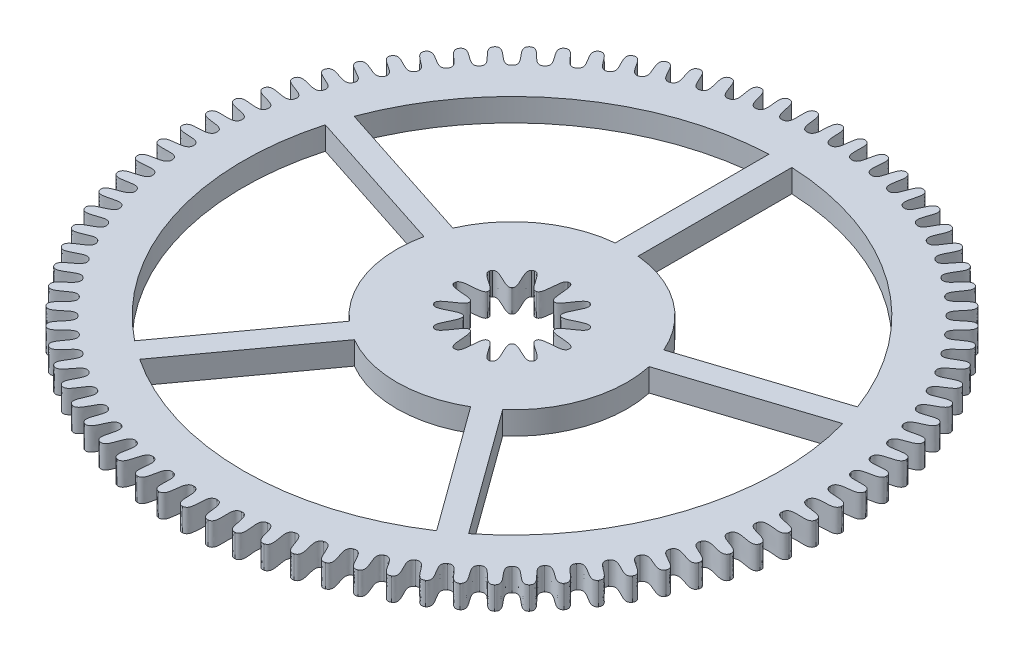
from build123d import *

# Parameters (mm, degrees)
BOSS_EXTRUDE1_84_TEETH_DEPTH = 0.3
CUT_EXTRUDE1_DEPTH           = 0.3
CUT_EXTRUDE2_REACH           = 2.3


with BuildPart() as part:
    # Sketch1 → Boss-Extrude1 (84 teeth) (new body)
    with BuildSketch(Plane(origin=(0, 0, 0), x_dir=(1, 0, 0), z_dir=(0, 1, 0))):
        with BuildLine():
            add(Edge.make_bspline(
                [(0, 4.315), (0.13525823, 4.312877026), (0.00799966, 4.016650924), (0.150125645, 4.01219233)],
                knots=[0, 0, 0, 0, 1, 1, 1, 1], degree=3))
            add(Edge.make_bspline(
                [(0.322460354, 4.302934385), (0.187421683, 4.310925207), (0.292187408, 4.006017369), (0.150125645, 4.01219233)],
                knots=[0, 0, 0, 0, 1, 1, 1, 1], degree=3))
            add(Edge.make_bspline(
                [(0.322460354, 4.302934385), (0.457181725, 4.290709487), (0.308141991, 4.004821739), (0.449537372, 3.989754523)],
                knots=[0, 0, 0, 0, 1, 1, 1, 1], degree=3))
            add(Edge.make_bspline(
                [(0.643117379, 4.266805015), (0.509053458, 4.284864946), (0.590740446, 3.97298054), (0.449537372, 3.989754523)],
                knots=[0, 0, 0, 0, 1, 1, 1, 1], degree=3))
            add(Edge.make_bspline(
                [(0.643117379, 4.266805015), (0.776548473, 4.24454656), (0.606561066, 3.970595965), (0.746435103, 3.94500439)],
                knots=[0, 0, 0, 0, 1, 1, 1, 1], degree=3))
            add(Edge.make_bspline(
                [(0.96017783, 4.206813941), (0.8278384, 4.234841982), (0.885989824, 3.917725192), (0.746435103, 3.94500439)],
                knots=[0, 0, 0, 0, 1, 1, 1, 1], degree=3))
            add(Edge.make_bspline(
                [(0.96017783, 4.206813941), (1.091572448, 4.174646407), (0.901588007, 3.914165008), (1.039158466, 3.878192193)],
                knots=[0, 0, 0, 0, 1, 1, 1, 1], degree=3))
            add(Edge.make_bspline(
                [(1.271868578, 4.123296657), (1.141993733, 4.161136064), (1.176284387, 3.840560335), (1.039158466, 3.878192193)],
                knots=[0, 0, 0, 0, 1, 1, 1, 1], degree=3))
            add(Edge.make_bspline(
                [(1.271868578, 4.123296657), (1.400491907, 4.081399938), (1.191572901, 3.835844453), (1.326070434, 3.789691571)],
                knots=[0, 0, 0, 0, 1, 1, 1, 1], degree=3))
            add(Edge.make_bspline(
                [(1.57644652, 4.016720225), (1.449762575, 4.064159385), (1.46000069, 3.741917507), (1.326070434, 3.789691571)],
                knots=[0, 0, 0, 0, 1, 1, 1, 1], degree=3))
            add(Edge.make_bspline(
                [(1.57644652, 4.016720225), (1.701579247, 3.965328624), (1.474894037, 3.736072299), (1.605566478, 3.679997457)],
                knots=[0, 0, 0, 0, 1, 1, 1, 1], degree=3))
            add(Edge.make_bspline(
                [(1.872208334, 3.887680665), (1.749423756, 3.944454278), (1.735552077, 3.622348358), (1.605566478, 3.679997457)],
                knots=[0, 0, 0, 0, 1, 1, 1, 1], degree=3))
            add(Edge.make_bspline(
                [(1.872208334, 3.887680665), (1.993150665, 3.827081585), (1.749966966, 3.615406514), (1.876083543, 3.549723305)],
                knots=[0, 0, 0, 0, 1, 1, 1, 1], degree=3))
            add(Edge.make_bspline(
                [(2.1575, 3.736899617), (2.03930145, 3.802690183), (2.001397554, 3.482521569), (1.876083543, 3.549723305)],
                knots=[0, 0, 0, 0, 1, 1, 1, 1], degree=3))
            add(Edge.make_bspline(
                [(2.1575, 3.736899617), (2.273575577, 3.667431953), (2.015253371, 3.474521909), (2.136108787, 3.39959766)],
                knots=[0, 0, 0, 0, 1, 1, 1, 1], degree=3))
            add(Edge.make_bspline(
                [(2.430726051, 3.565220311), (2.317774542, 3.639659902), (2.256050403, 3.323219105), (2.136108787, 3.39959766)],
                knots=[0, 0, 0, 0, 1, 1, 1, 1], degree=3))
            add(Edge.make_bspline(
                [(2.430726051, 3.565220311), (2.541285731, 3.487272554), (2.269269661, 3.314206368), (2.384188045, 3.230460086)],
                knots=[0, 0, 0, 0, 1, 1, 1, 1], degree=3))
            add(Edge.make_bspline(
                [(2.690358495, 3.373602847), (2.5832857, 3.456275166), (2.498086503, 3.145331853), (2.384188045, 3.230460086)],
                knots=[0, 0, 0, 0, 1, 1, 1, 1], degree=3))
            add(Edge.make_bspline(
                [(2.690358495, 3.373602847), (2.794783985, 3.287610912), (2.510595275, 3.135356441), (2.618933956, 3.043256468)],
                knots=[0, 0, 0, 0, 1, 1, 1, 1], degree=3))
            add(Edge.make_bspline(
                [(2.934945363, 3.163118827), (2.834350076, 3.253561538), (2.72615229, 2.949854629), (2.618933956, 3.043256468)],
                knots=[0, 0, 0, 0, 1, 1, 1, 1], degree=3))
            add(Edge.make_bspline(
                [(2.934945363, 3.163118827), (3.032652673, 3.069563616), (2.737880622, 2.938972328), (2.839033726, 2.839033726)],
                knots=[0, 0, 0, 0, 1, 1, 1, 1], degree=3))
            add(Edge.make_bspline(
                [(3.163118827, 2.934945363), (3.069563616, 3.032652673), (2.938972328, 2.737880622), (2.839033726, 2.839033726)],
                knots=[0, 0, 0, 0, 1, 1, 1, 1], degree=3))
            add(Edge.make_bspline(
                [(3.163118827, 2.934945363), (3.253561538, 2.834350076), (2.949854629, 2.72615229), (3.043256468, 2.618933956)],
                knots=[0, 0, 0, 0, 1, 1, 1, 1], degree=3))
            add(Edge.make_bspline(
                [(3.373602847, 2.690358495), (3.287610912, 2.794783985), (3.135356441, 2.510595275), (3.043256468, 2.618933956)],
                knots=[0, 0, 0, 0, 1, 1, 1, 1], degree=3))
            add(Edge.make_bspline(
                [(3.373602847, 2.690358495), (3.456275166, 2.5832857), (3.145331853, 2.498086503), (3.230460086, 2.384188045)],
                knots=[0, 0, 0, 0, 1, 1, 1, 1], degree=3))
            add(Edge.make_bspline(
                [(3.565220311, 2.430726051), (3.487272554, 2.541285731), (3.314206368, 2.269269661), (3.230460086, 2.384188045)],
                knots=[0, 0, 0, 0, 1, 1, 1, 1], degree=3))
            add(Edge.make_bspline(
                [(3.565220311, 2.430726051), (3.639659902, 2.317774542), (3.323219105, 2.256050403), (3.39959766, 2.136108787)],
                knots=[0, 0, 0, 0, 1, 1, 1, 1], degree=3))
            add(Edge.make_bspline(
                [(3.736899617, 2.1575), (3.667431953, 2.273575577), (3.474521909, 2.015253371), (3.39959766, 2.136108787)],
                knots=[0, 0, 0, 0, 1, 1, 1, 1], degree=3))
            add(Edge.make_bspline(
                [(3.736899617, 2.1575), (3.802690183, 2.03930145), (3.482521569, 2.001397554), (3.549723305, 1.876083543)],
                knots=[0, 0, 0, 0, 1, 1, 1, 1], degree=3))
            add(Edge.make_bspline(
                [(3.887680665, 1.872208334), (3.827081585, 1.993150665), (3.615406514, 1.749966966), (3.549723305, 1.876083543)],
                knots=[0, 0, 0, 0, 1, 1, 1, 1], degree=3))
            add(Edge.make_bspline(
                [(3.887680665, 1.872208334), (3.944454278, 1.749423756), (3.622348358, 1.735552077), (3.679997457, 1.605566478)],
                knots=[0, 0, 0, 0, 1, 1, 1, 1], degree=3))
            add(Edge.make_bspline(
                [(4.016720225, 1.57644652), (3.965328624, 1.701579247), (3.736072299, 1.474894037), (3.679997457, 1.605566478)],
                knots=[0, 0, 0, 0, 1, 1, 1, 1], degree=3))
            add(Edge.make_bspline(
                [(4.016720225, 1.57644652), (4.064159385, 1.449762575), (3.741917507, 1.46000069), (3.789691571, 1.326070434)],
                knots=[0, 0, 0, 0, 1, 1, 1, 1], degree=3))
            add(Edge.make_bspline(
                [(4.123296657, 1.271868578), (4.081399938, 1.400491907), (3.835844453, 1.191572901), (3.789691571, 1.326070434)],
                knots=[0, 0, 0, 0, 1, 1, 1, 1], degree=3))
            add(Edge.make_bspline(
                [(4.123296657, 1.271868578), (4.161136064, 1.141993733), (3.840560335, 1.176284387), (3.878192193, 1.039158466)],
                knots=[0, 0, 0, 0, 1, 1, 1, 1], degree=3))
            add(Edge.make_bspline(
                [(4.206813941, 0.96017783), (4.174646407, 1.091572448), (3.914165008, 0.901588007), (3.878192193, 1.039158466)],
                knots=[0, 0, 0, 0, 1, 1, 1, 1], degree=3))
            add(Edge.make_bspline(
                [(4.206813941, 0.96017783), (4.234841982, 0.8278384), (3.917725192, 0.885989824), (3.94500439, 0.746435103)],
                knots=[0, 0, 0, 0, 1, 1, 1, 1], degree=3))
            add(Edge.make_bspline(
                [(4.266805015, 0.643117379), (4.24454656, 0.776548473), (3.970595965, 0.606561066), (3.94500439, 0.746435103)],
                knots=[0, 0, 0, 0, 1, 1, 1, 1], degree=3))
            add(Edge.make_bspline(
                [(4.266805015, 0.643117379), (4.284864946, 0.509053458), (3.97298054, 0.590740446), (3.989754523, 0.449537372)],
                knots=[0, 0, 0, 0, 1, 1, 1, 1], degree=3))
            add(Edge.make_bspline(
                [(4.302934385, 0.322460354), (4.290709487, 0.457181725), (4.004821739, 0.308141991), (3.989754523, 0.449537372)],
                knots=[0, 0, 0, 0, 1, 1, 1, 1], degree=3))
            add(Edge.make_bspline(
                [(4.302934385, 0.322460354), (4.310925207, 0.187421683), (4.006017369, 0.292187408), (4.01219233, 0.150125645)],
                knots=[0, 0, 0, 0, 1, 1, 1, 1], degree=3))
            add(Edge.make_bspline(
                [(4.315, 0), (4.312877026, 0.13525823), (4.016650924, 0.00799966), (4.01219233, 0.150125645)],
                knots=[0, 0, 0, 0, 1, 1, 1, 1], degree=3))
            add(Edge.make_bspline(
                [(4.315, 0), (4.312877026, -0.13525823), (4.016650924, -0.00799966), (4.01219233, -0.150125645)],
                knots=[0, 0, 0, 0, 1, 1, 1, 1], degree=3))
            add(Edge.make_bspline(
                [(4.302934385, -0.322460354), (4.310925207, -0.187421683), (4.006017369, -0.292187408), (4.01219233, -0.150125645)],
                knots=[0, 0, 0, 0, 1, 1, 1, 1], degree=3))
            add(Edge.make_bspline(
                [(4.302934385, -0.322460354), (4.290709487, -0.457181725), (4.004821739, -0.308141991), (3.989754523, -0.449537372)],
                knots=[0, 0, 0, 0, 1, 1, 1, 1], degree=3))
            add(Edge.make_bspline(
                [(4.266805015, -0.643117379), (4.284864946, -0.509053458), (3.97298054, -0.590740446), (3.989754523, -0.449537372)],
                knots=[0, 0, 0, 0, 1, 1, 1, 1], degree=3))
            add(Edge.make_bspline(
                [(4.266805015, -0.643117379), (4.24454656, -0.776548473), (3.970595965, -0.606561066), (3.94500439, -0.746435103)],
                knots=[0, 0, 0, 0, 1, 1, 1, 1], degree=3))
            add(Edge.make_bspline(
                [(4.206813941, -0.96017783), (4.234841982, -0.8278384), (3.917725192, -0.885989824), (3.94500439, -0.746435103)],
                knots=[0, 0, 0, 0, 1, 1, 1, 1], degree=3))
            add(Edge.make_bspline(
                [(4.206813941, -0.96017783), (4.174646407, -1.091572448), (3.914165008, -0.901588007), (3.878192193, -1.039158466)],
                knots=[0, 0, 0, 0, 1, 1, 1, 1], degree=3))
            add(Edge.make_bspline(
                [(4.123296657, -1.271868578), (4.161136064, -1.141993733), (3.840560335, -1.176284387), (3.878192193, -1.039158466)],
                knots=[0, 0, 0, 0, 1, 1, 1, 1], degree=3))
            add(Edge.make_bspline(
                [(4.123296657, -1.271868578), (4.081399938, -1.400491907), (3.835844453, -1.191572901), (3.789691571, -1.326070434)],
                knots=[0, 0, 0, 0, 1, 1, 1, 1], degree=3))
            add(Edge.make_bspline(
                [(4.016720225, -1.57644652), (4.064159385, -1.449762575), (3.741917507, -1.46000069), (3.789691571, -1.326070434)],
                knots=[0, 0, 0, 0, 1, 1, 1, 1], degree=3))
            add(Edge.make_bspline(
                [(4.016720225, -1.57644652), (3.965328624, -1.701579247), (3.736072299, -1.474894037), (3.679997457, -1.605566478)],
                knots=[0, 0, 0, 0, 1, 1, 1, 1], degree=3))
            add(Edge.make_bspline(
                [(3.887680665, -1.872208334), (3.944454278, -1.749423756), (3.622348358, -1.735552077), (3.679997457, -1.605566478)],
                knots=[0, 0, 0, 0, 1, 1, 1, 1], degree=3))
            add(Edge.make_bspline(
                [(3.887680665, -1.872208334), (3.827081585, -1.993150665), (3.615406514, -1.749966966), (3.549723305, -1.876083543)],
                knots=[0, 0, 0, 0, 1, 1, 1, 1], degree=3))
            add(Edge.make_bspline(
                [(3.736899617, -2.1575), (3.802690183, -2.03930145), (3.482521569, -2.001397554), (3.549723305, -1.876083543)],
                knots=[0, 0, 0, 0, 1, 1, 1, 1], degree=3))
            add(Edge.make_bspline(
                [(3.736899617, -2.1575), (3.667431953, -2.273575577), (3.474521909, -2.015253371), (3.39959766, -2.136108787)],
                knots=[0, 0, 0, 0, 1, 1, 1, 1], degree=3))
            add(Edge.make_bspline(
                [(3.565220311, -2.430726051), (3.639659902, -2.317774542), (3.323219105, -2.256050403), (3.39959766, -2.136108787)],
                knots=[0, 0, 0, 0, 1, 1, 1, 1], degree=3))
            add(Edge.make_bspline(
                [(3.565220311, -2.430726051), (3.487272554, -2.541285731), (3.314206368, -2.269269661), (3.230460086, -2.384188045)],
                knots=[0, 0, 0, 0, 1, 1, 1, 1], degree=3))
            add(Edge.make_bspline(
                [(3.373602847, -2.690358495), (3.456275166, -2.5832857), (3.145331853, -2.498086503), (3.230460086, -2.384188045)],
                knots=[0, 0, 0, 0, 1, 1, 1, 1], degree=3))
            add(Edge.make_bspline(
                [(3.373602847, -2.690358495), (3.287610912, -2.794783985), (3.135356441, -2.510595275), (3.043256468, -2.618933956)],
                knots=[0, 0, 0, 0, 1, 1, 1, 1], degree=3))
            add(Edge.make_bspline(
                [(3.163118827, -2.934945363), (3.253561538, -2.834350076), (2.949854629, -2.72615229), (3.043256468, -2.618933956)],
                knots=[0, 0, 0, 0, 1, 1, 1, 1], degree=3))
            add(Edge.make_bspline(
                [(3.163118827, -2.934945363), (3.069563616, -3.032652673), (2.938972328, -2.737880622), (2.839033726, -2.839033726)],
                knots=[0, 0, 0, 0, 1, 1, 1, 1], degree=3))
            add(Edge.make_bspline(
                [(2.934945363, -3.163118827), (3.032652673, -3.069563616), (2.737880622, -2.938972328), (2.839033726, -2.839033726)],
                knots=[0, 0, 0, 0, 1, 1, 1, 1], degree=3))
            add(Edge.make_bspline(
                [(2.934945363, -3.163118827), (2.834350076, -3.253561538), (2.72615229, -2.949854629), (2.618933956, -3.043256468)],
                knots=[0, 0, 0, 0, 1, 1, 1, 1], degree=3))
            add(Edge.make_bspline(
                [(2.690358495, -3.373602847), (2.794783985, -3.287610912), (2.510595275, -3.135356441), (2.618933956, -3.043256468)],
                knots=[0, 0, 0, 0, 1, 1, 1, 1], degree=3))
            add(Edge.make_bspline(
                [(2.690358495, -3.373602847), (2.5832857, -3.456275166), (2.498086503, -3.145331853), (2.384188045, -3.230460086)],
                knots=[0, 0, 0, 0, 1, 1, 1, 1], degree=3))
            add(Edge.make_bspline(
                [(2.430726051, -3.565220311), (2.541285731, -3.487272554), (2.269269661, -3.314206368), (2.384188045, -3.230460086)],
                knots=[0, 0, 0, 0, 1, 1, 1, 1], degree=3))
            add(Edge.make_bspline(
                [(2.430726051, -3.565220311), (2.317774542, -3.639659902), (2.256050403, -3.323219105), (2.136108787, -3.39959766)],
                knots=[0, 0, 0, 0, 1, 1, 1, 1], degree=3))
            add(Edge.make_bspline(
                [(2.1575, -3.736899617), (2.273575577, -3.667431953), (2.015253371, -3.474521909), (2.136108787, -3.39959766)],
                knots=[0, 0, 0, 0, 1, 1, 1, 1], degree=3))
            add(Edge.make_bspline(
                [(2.1575, -3.736899617), (2.03930145, -3.802690183), (2.001397554, -3.482521569), (1.876083543, -3.549723305)],
                knots=[0, 0, 0, 0, 1, 1, 1, 1], degree=3))
            add(Edge.make_bspline(
                [(1.872208334, -3.887680665), (1.993150665, -3.827081585), (1.749966966, -3.615406514), (1.876083543, -3.549723305)],
                knots=[0, 0, 0, 0, 1, 1, 1, 1], degree=3))
            add(Edge.make_bspline(
                [(1.872208334, -3.887680665), (1.749423756, -3.944454278), (1.735552077, -3.622348358), (1.605566478, -3.679997457)],
                knots=[0, 0, 0, 0, 1, 1, 1, 1], degree=3))
            add(Edge.make_bspline(
                [(1.57644652, -4.016720225), (1.701579247, -3.965328624), (1.474894037, -3.736072299), (1.605566478, -3.679997457)],
                knots=[0, 0, 0, 0, 1, 1, 1, 1], degree=3))
            add(Edge.make_bspline(
                [(1.57644652, -4.016720225), (1.449762575, -4.064159385), (1.46000069, -3.741917507), (1.326070434, -3.789691571)],
                knots=[0, 0, 0, 0, 1, 1, 1, 1], degree=3))
            add(Edge.make_bspline(
                [(1.271868578, -4.123296657), (1.400491907, -4.081399938), (1.191572901, -3.835844453), (1.326070434, -3.789691571)],
                knots=[0, 0, 0, 0, 1, 1, 1, 1], degree=3))
            add(Edge.make_bspline(
                [(1.271868578, -4.123296657), (1.141993733, -4.161136064), (1.176284387, -3.840560335), (1.039158466, -3.878192193)],
                knots=[0, 0, 0, 0, 1, 1, 1, 1], degree=3))
            add(Edge.make_bspline(
                [(0.96017783, -4.206813941), (1.091572448, -4.174646407), (0.901588007, -3.914165008), (1.039158466, -3.878192193)],
                knots=[0, 0, 0, 0, 1, 1, 1, 1], degree=3))
            add(Edge.make_bspline(
                [(0.96017783, -4.206813941), (0.8278384, -4.234841982), (0.885989824, -3.917725192), (0.746435103, -3.94500439)],
                knots=[0, 0, 0, 0, 1, 1, 1, 1], degree=3))
            add(Edge.make_bspline(
                [(0.643117379, -4.266805015), (0.776548473, -4.24454656), (0.606561066, -3.970595965), (0.746435103, -3.94500439)],
                knots=[0, 0, 0, 0, 1, 1, 1, 1], degree=3))
            add(Edge.make_bspline(
                [(0.643117379, -4.266805015), (0.509053458, -4.284864946), (0.590740446, -3.97298054), (0.449537372, -3.989754523)],
                knots=[0, 0, 0, 0, 1, 1, 1, 1], degree=3))
            add(Edge.make_bspline(
                [(0.322460354, -4.302934385), (0.457181725, -4.290709487), (0.308141991, -4.004821739), (0.449537372, -3.989754523)],
                knots=[0, 0, 0, 0, 1, 1, 1, 1], degree=3))
            add(Edge.make_bspline(
                [(0.322460354, -4.302934385), (0.187421683, -4.310925207), (0.292187408, -4.006017369), (0.150125645, -4.01219233)],
                knots=[0, 0, 0, 0, 1, 1, 1, 1], degree=3))
            add(Edge.make_bspline(
                [(0, -4.315), (0.13525823, -4.312877026), (0.00799966, -4.016650924), (0.150125645, -4.01219233)],
                knots=[0, 0, 0, 0, 1, 1, 1, 1], degree=3))
            add(Edge.make_bspline(
                [(0, -4.315), (-0.13525823, -4.312877026), (-0.00799966, -4.016650924), (-0.150125645, -4.01219233)],
                knots=[0, 0, 0, 0, 1, 1, 1, 1], degree=3))
            add(Edge.make_bspline(
                [(-0.322460354, -4.302934385), (-0.187421683, -4.310925207), (-0.292187408, -4.006017369), (-0.150125645, -4.01219233)],
                knots=[0, 0, 0, 0, 1, 1, 1, 1], degree=3))
            add(Edge.make_bspline(
                [(-0.322460354, -4.302934385), (-0.457181725, -4.290709487), (-0.308141991, -4.004821739), (-0.449537372, -3.989754523)],
                knots=[0, 0, 0, 0, 1, 1, 1, 1], degree=3))
            add(Edge.make_bspline(
                [(-0.643117379, -4.266805015), (-0.509053458, -4.284864946), (-0.590740446, -3.97298054), (-0.449537372, -3.989754523)],
                knots=[0, 0, 0, 0, 1, 1, 1, 1], degree=3))
            add(Edge.make_bspline(
                [(-0.643117379, -4.266805015), (-0.776548473, -4.24454656), (-0.606561066, -3.970595965), (-0.746435103, -3.94500439)],
                knots=[0, 0, 0, 0, 1, 1, 1, 1], degree=3))
            add(Edge.make_bspline(
                [(-0.96017783, -4.206813941), (-0.8278384, -4.234841982), (-0.885989824, -3.917725192), (-0.746435103, -3.94500439)],
                knots=[0, 0, 0, 0, 1, 1, 1, 1], degree=3))
            add(Edge.make_bspline(
                [(-0.96017783, -4.206813941), (-1.091572448, -4.174646407), (-0.901588007, -3.914165008), (-1.039158466, -3.878192193)],
                knots=[0, 0, 0, 0, 1, 1, 1, 1], degree=3))
            add(Edge.make_bspline(
                [(-1.271868578, -4.123296657), (-1.141993733, -4.161136064), (-1.176284387, -3.840560335), (-1.039158466, -3.878192193)],
                knots=[0, 0, 0, 0, 1, 1, 1, 1], degree=3))
            add(Edge.make_bspline(
                [(-1.271868578, -4.123296657), (-1.400491907, -4.081399938), (-1.191572901, -3.835844453), (-1.326070434, -3.789691571)],
                knots=[0, 0, 0, 0, 1, 1, 1, 1], degree=3))
            add(Edge.make_bspline(
                [(-1.57644652, -4.016720225), (-1.449762575, -4.064159385), (-1.46000069, -3.741917507), (-1.326070434, -3.789691571)],
                knots=[0, 0, 0, 0, 1, 1, 1, 1], degree=3))
            add(Edge.make_bspline(
                [(-1.57644652, -4.016720225), (-1.701579247, -3.965328624), (-1.474894037, -3.736072299), (-1.605566478, -3.679997457)],
                knots=[0, 0, 0, 0, 1, 1, 1, 1], degree=3))
            add(Edge.make_bspline(
                [(-1.872208334, -3.887680665), (-1.749423756, -3.944454278), (-1.735552077, -3.622348358), (-1.605566478, -3.679997457)],
                knots=[0, 0, 0, 0, 1, 1, 1, 1], degree=3))
            add(Edge.make_bspline(
                [(-1.872208334, -3.887680665), (-1.993150665, -3.827081585), (-1.749966966, -3.615406514), (-1.876083543, -3.549723305)],
                knots=[0, 0, 0, 0, 1, 1, 1, 1], degree=3))
            add(Edge.make_bspline(
                [(-2.1575, -3.736899617), (-2.03930145, -3.802690183), (-2.001397554, -3.482521569), (-1.876083543, -3.549723305)],
                knots=[0, 0, 0, 0, 1, 1, 1, 1], degree=3))
            add(Edge.make_bspline(
                [(-2.1575, -3.736899617), (-2.273575577, -3.667431953), (-2.015253371, -3.474521909), (-2.136108787, -3.39959766)],
                knots=[0, 0, 0, 0, 1, 1, 1, 1], degree=3))
            add(Edge.make_bspline(
                [(-2.430726051, -3.565220311), (-2.317774542, -3.639659902), (-2.256050403, -3.323219105), (-2.136108787, -3.39959766)],
                knots=[0, 0, 0, 0, 1, 1, 1, 1], degree=3))
            add(Edge.make_bspline(
                [(-2.430726051, -3.565220311), (-2.541285731, -3.487272554), (-2.269269661, -3.314206368), (-2.384188045, -3.230460086)],
                knots=[0, 0, 0, 0, 1, 1, 1, 1], degree=3))
            add(Edge.make_bspline(
                [(-2.690358495, -3.373602847), (-2.5832857, -3.456275166), (-2.498086503, -3.145331853), (-2.384188045, -3.230460086)],
                knots=[0, 0, 0, 0, 1, 1, 1, 1], degree=3))
            add(Edge.make_bspline(
                [(-2.690358495, -3.373602847), (-2.794783985, -3.287610912), (-2.510595275, -3.135356441), (-2.618933956, -3.043256468)],
                knots=[0, 0, 0, 0, 1, 1, 1, 1], degree=3))
            add(Edge.make_bspline(
                [(-2.934945363, -3.163118827), (-2.834350076, -3.253561538), (-2.72615229, -2.949854629), (-2.618933956, -3.043256468)],
                knots=[0, 0, 0, 0, 1, 1, 1, 1], degree=3))
            add(Edge.make_bspline(
                [(-2.934945363, -3.163118827), (-3.032652673, -3.069563616), (-2.737880622, -2.938972328), (-2.839033726, -2.839033726)],
                knots=[0, 0, 0, 0, 1, 1, 1, 1], degree=3))
            add(Edge.make_bspline(
                [(-3.163118827, -2.934945363), (-3.069563616, -3.032652673), (-2.938972328, -2.737880622), (-2.839033726, -2.839033726)],
                knots=[0, 0, 0, 0, 1, 1, 1, 1], degree=3))
            add(Edge.make_bspline(
                [(-3.163118827, -2.934945363), (-3.253561538, -2.834350076), (-2.949854629, -2.72615229), (-3.043256468, -2.618933956)],
                knots=[0, 0, 0, 0, 1, 1, 1, 1], degree=3))
            add(Edge.make_bspline(
                [(-3.373602847, -2.690358495), (-3.287610912, -2.794783985), (-3.135356441, -2.510595275), (-3.043256468, -2.618933956)],
                knots=[0, 0, 0, 0, 1, 1, 1, 1], degree=3))
            add(Edge.make_bspline(
                [(-3.373602847, -2.690358495), (-3.456275166, -2.5832857), (-3.145331853, -2.498086503), (-3.230460086, -2.384188045)],
                knots=[0, 0, 0, 0, 1, 1, 1, 1], degree=3))
            add(Edge.make_bspline(
                [(-3.565220311, -2.430726051), (-3.487272554, -2.541285731), (-3.314206368, -2.269269661), (-3.230460086, -2.384188045)],
                knots=[0, 0, 0, 0, 1, 1, 1, 1], degree=3))
            add(Edge.make_bspline(
                [(-3.565220311, -2.430726051), (-3.639659902, -2.317774542), (-3.323219105, -2.256050403), (-3.39959766, -2.136108787)],
                knots=[0, 0, 0, 0, 1, 1, 1, 1], degree=3))
            add(Edge.make_bspline(
                [(-3.736899617, -2.1575), (-3.667431953, -2.273575577), (-3.474521909, -2.015253371), (-3.39959766, -2.136108787)],
                knots=[0, 0, 0, 0, 1, 1, 1, 1], degree=3))
            add(Edge.make_bspline(
                [(-3.736899617, -2.1575), (-3.802690183, -2.03930145), (-3.482521569, -2.001397554), (-3.549723305, -1.876083543)],
                knots=[0, 0, 0, 0, 1, 1, 1, 1], degree=3))
            add(Edge.make_bspline(
                [(-3.887680665, -1.872208334), (-3.827081585, -1.993150665), (-3.615406514, -1.749966966), (-3.549723305, -1.876083543)],
                knots=[0, 0, 0, 0, 1, 1, 1, 1], degree=3))
            add(Edge.make_bspline(
                [(-3.887680665, -1.872208334), (-3.944454278, -1.749423756), (-3.622348358, -1.735552077), (-3.679997457, -1.605566478)],
                knots=[0, 0, 0, 0, 1, 1, 1, 1], degree=3))
            add(Edge.make_bspline(
                [(-4.016720225, -1.57644652), (-3.965328624, -1.701579247), (-3.736072299, -1.474894037), (-3.679997457, -1.605566478)],
                knots=[0, 0, 0, 0, 1, 1, 1, 1], degree=3))
            add(Edge.make_bspline(
                [(-4.016720225, -1.57644652), (-4.064159385, -1.449762575), (-3.741917507, -1.46000069), (-3.789691571, -1.326070434)],
                knots=[0, 0, 0, 0, 1, 1, 1, 1], degree=3))
            add(Edge.make_bspline(
                [(-4.123296657, -1.271868578), (-4.081399938, -1.400491907), (-3.835844453, -1.191572901), (-3.789691571, -1.326070434)],
                knots=[0, 0, 0, 0, 1, 1, 1, 1], degree=3))
            add(Edge.make_bspline(
                [(-4.123296657, -1.271868578), (-4.161136064, -1.141993733), (-3.840560335, -1.176284387), (-3.878192193, -1.039158466)],
                knots=[0, 0, 0, 0, 1, 1, 1, 1], degree=3))
            add(Edge.make_bspline(
                [(-4.206813941, -0.96017783), (-4.174646407, -1.091572448), (-3.914165008, -0.901588007), (-3.878192193, -1.039158466)],
                knots=[0, 0, 0, 0, 1, 1, 1, 1], degree=3))
            add(Edge.make_bspline(
                [(-4.206813941, -0.96017783), (-4.234841982, -0.8278384), (-3.917725192, -0.885989824), (-3.94500439, -0.746435103)],
                knots=[0, 0, 0, 0, 1, 1, 1, 1], degree=3))
            add(Edge.make_bspline(
                [(-4.266805015, -0.643117379), (-4.24454656, -0.776548473), (-3.970595965, -0.606561066), (-3.94500439, -0.746435103)],
                knots=[0, 0, 0, 0, 1, 1, 1, 1], degree=3))
            add(Edge.make_bspline(
                [(-4.266805015, -0.643117379), (-4.284864946, -0.509053458), (-3.97298054, -0.590740446), (-3.989754523, -0.449537372)],
                knots=[0, 0, 0, 0, 1, 1, 1, 1], degree=3))
            add(Edge.make_bspline(
                [(-4.302934385, -0.322460354), (-4.290709487, -0.457181725), (-4.004821739, -0.308141991), (-3.989754523, -0.449537372)],
                knots=[0, 0, 0, 0, 1, 1, 1, 1], degree=3))
            add(Edge.make_bspline(
                [(-4.302934385, -0.322460354), (-4.310925207, -0.187421683), (-4.006017369, -0.292187408), (-4.01219233, -0.150125645)],
                knots=[0, 0, 0, 0, 1, 1, 1, 1], degree=3))
            add(Edge.make_bspline(
                [(-4.315, 0), (-4.312877026, -0.13525823), (-4.016650924, -0.00799966), (-4.01219233, -0.150125645)],
                knots=[0, 0, 0, 0, 1, 1, 1, 1], degree=3))
            add(Edge.make_bspline(
                [(-4.315, 0), (-4.312877026, 0.13525823), (-4.016650924, 0.00799966), (-4.01219233, 0.150125645)],
                knots=[0, 0, 0, 0, 1, 1, 1, 1], degree=3))
            add(Edge.make_bspline(
                [(-4.302934385, 0.322460354), (-4.310925207, 0.187421683), (-4.006017369, 0.292187408), (-4.01219233, 0.150125645)],
                knots=[0, 0, 0, 0, 1, 1, 1, 1], degree=3))
            add(Edge.make_bspline(
                [(-4.302934385, 0.322460354), (-4.290709487, 0.457181725), (-4.004821739, 0.308141991), (-3.989754523, 0.449537372)],
                knots=[0, 0, 0, 0, 1, 1, 1, 1], degree=3))
            add(Edge.make_bspline(
                [(-4.266805015, 0.643117379), (-4.284864946, 0.509053458), (-3.97298054, 0.590740446), (-3.989754523, 0.449537372)],
                knots=[0, 0, 0, 0, 1, 1, 1, 1], degree=3))
            add(Edge.make_bspline(
                [(-4.266805015, 0.643117379), (-4.24454656, 0.776548473), (-3.970595965, 0.606561066), (-3.94500439, 0.746435103)],
                knots=[0, 0, 0, 0, 1, 1, 1, 1], degree=3))
            add(Edge.make_bspline(
                [(-4.206813941, 0.96017783), (-4.234841982, 0.8278384), (-3.917725192, 0.885989824), (-3.94500439, 0.746435103)],
                knots=[0, 0, 0, 0, 1, 1, 1, 1], degree=3))
            add(Edge.make_bspline(
                [(-4.206813941, 0.96017783), (-4.174646407, 1.091572448), (-3.914165008, 0.901588007), (-3.878192193, 1.039158466)],
                knots=[0, 0, 0, 0, 1, 1, 1, 1], degree=3))
            add(Edge.make_bspline(
                [(-4.123296657, 1.271868578), (-4.161136064, 1.141993733), (-3.840560335, 1.176284387), (-3.878192193, 1.039158466)],
                knots=[0, 0, 0, 0, 1, 1, 1, 1], degree=3))
            add(Edge.make_bspline(
                [(-4.123296657, 1.271868578), (-4.081399938, 1.400491907), (-3.835844453, 1.191572901), (-3.789691571, 1.326070434)],
                knots=[0, 0, 0, 0, 1, 1, 1, 1], degree=3))
            add(Edge.make_bspline(
                [(-4.016720225, 1.57644652), (-4.064159385, 1.449762575), (-3.741917507, 1.46000069), (-3.789691571, 1.326070434)],
                knots=[0, 0, 0, 0, 1, 1, 1, 1], degree=3))
            add(Edge.make_bspline(
                [(-4.016720225, 1.57644652), (-3.965328624, 1.701579247), (-3.736072299, 1.474894037), (-3.679997457, 1.605566478)],
                knots=[0, 0, 0, 0, 1, 1, 1, 1], degree=3))
            add(Edge.make_bspline(
                [(-3.887680665, 1.872208334), (-3.944454278, 1.749423756), (-3.622348358, 1.735552077), (-3.679997457, 1.605566478)],
                knots=[0, 0, 0, 0, 1, 1, 1, 1], degree=3))
            add(Edge.make_bspline(
                [(-3.887680665, 1.872208334), (-3.827081585, 1.993150665), (-3.615406514, 1.749966966), (-3.549723305, 1.876083543)],
                knots=[0, 0, 0, 0, 1, 1, 1, 1], degree=3))
            add(Edge.make_bspline(
                [(-3.736899617, 2.1575), (-3.802690183, 2.03930145), (-3.482521569, 2.001397554), (-3.549723305, 1.876083543)],
                knots=[0, 0, 0, 0, 1, 1, 1, 1], degree=3))
            add(Edge.make_bspline(
                [(-3.736899617, 2.1575), (-3.667431953, 2.273575577), (-3.474521909, 2.015253371), (-3.39959766, 2.136108787)],
                knots=[0, 0, 0, 0, 1, 1, 1, 1], degree=3))
            add(Edge.make_bspline(
                [(-3.565220311, 2.430726051), (-3.639659902, 2.317774542), (-3.323219105, 2.256050403), (-3.39959766, 2.136108787)],
                knots=[0, 0, 0, 0, 1, 1, 1, 1], degree=3))
            add(Edge.make_bspline(
                [(-3.565220311, 2.430726051), (-3.487272554, 2.541285731), (-3.314206368, 2.269269661), (-3.230460086, 2.384188045)],
                knots=[0, 0, 0, 0, 1, 1, 1, 1], degree=3))
            add(Edge.make_bspline(
                [(-3.373602847, 2.690358495), (-3.456275166, 2.5832857), (-3.145331853, 2.498086503), (-3.230460086, 2.384188045)],
                knots=[0, 0, 0, 0, 1, 1, 1, 1], degree=3))
            add(Edge.make_bspline(
                [(-3.373602847, 2.690358495), (-3.287610912, 2.794783985), (-3.135356441, 2.510595275), (-3.043256468, 2.618933956)],
                knots=[0, 0, 0, 0, 1, 1, 1, 1], degree=3))
            add(Edge.make_bspline(
                [(-3.163118827, 2.934945363), (-3.253561538, 2.834350076), (-2.949854629, 2.72615229), (-3.043256468, 2.618933956)],
                knots=[0, 0, 0, 0, 1, 1, 1, 1], degree=3))
            add(Edge.make_bspline(
                [(-3.163118827, 2.934945363), (-3.069563616, 3.032652673), (-2.938972328, 2.737880622), (-2.839033726, 2.839033726)],
                knots=[0, 0, 0, 0, 1, 1, 1, 1], degree=3))
            add(Edge.make_bspline(
                [(-2.934945363, 3.163118827), (-3.032652673, 3.069563616), (-2.737880622, 2.938972328), (-2.839033726, 2.839033726)],
                knots=[0, 0, 0, 0, 1, 1, 1, 1], degree=3))
            add(Edge.make_bspline(
                [(-2.934945363, 3.163118827), (-2.834350076, 3.253561538), (-2.72615229, 2.949854629), (-2.618933956, 3.043256468)],
                knots=[0, 0, 0, 0, 1, 1, 1, 1], degree=3))
            add(Edge.make_bspline(
                [(-2.690358495, 3.373602847), (-2.794783985, 3.287610912), (-2.510595275, 3.135356441), (-2.618933956, 3.043256468)],
                knots=[0, 0, 0, 0, 1, 1, 1, 1], degree=3))
            add(Edge.make_bspline(
                [(-2.690358495, 3.373602847), (-2.5832857, 3.456275166), (-2.498086503, 3.145331853), (-2.384188045, 3.230460086)],
                knots=[0, 0, 0, 0, 1, 1, 1, 1], degree=3))
            add(Edge.make_bspline(
                [(-2.430726051, 3.565220311), (-2.541285731, 3.487272554), (-2.269269661, 3.314206368), (-2.384188045, 3.230460086)],
                knots=[0, 0, 0, 0, 1, 1, 1, 1], degree=3))
            add(Edge.make_bspline(
                [(-2.430726051, 3.565220311), (-2.317774542, 3.639659902), (-2.256050403, 3.323219105), (-2.136108787, 3.39959766)],
                knots=[0, 0, 0, 0, 1, 1, 1, 1], degree=3))
            add(Edge.make_bspline(
                [(-2.1575, 3.736899617), (-2.273575577, 3.667431953), (-2.015253371, 3.474521909), (-2.136108787, 3.39959766)],
                knots=[0, 0, 0, 0, 1, 1, 1, 1], degree=3))
            add(Edge.make_bspline(
                [(-2.1575, 3.736899617), (-2.03930145, 3.802690183), (-2.001397554, 3.482521569), (-1.876083543, 3.549723305)],
                knots=[0, 0, 0, 0, 1, 1, 1, 1], degree=3))
            add(Edge.make_bspline(
                [(-1.872208334, 3.887680665), (-1.993150665, 3.827081585), (-1.749966966, 3.615406514), (-1.876083543, 3.549723305)],
                knots=[0, 0, 0, 0, 1, 1, 1, 1], degree=3))
            add(Edge.make_bspline(
                [(-1.872208334, 3.887680665), (-1.749423756, 3.944454278), (-1.735552077, 3.622348358), (-1.605566478, 3.679997457)],
                knots=[0, 0, 0, 0, 1, 1, 1, 1], degree=3))
            add(Edge.make_bspline(
                [(-1.57644652, 4.016720225), (-1.701579247, 3.965328624), (-1.474894037, 3.736072299), (-1.605566478, 3.679997457)],
                knots=[0, 0, 0, 0, 1, 1, 1, 1], degree=3))
            add(Edge.make_bspline(
                [(-1.57644652, 4.016720225), (-1.449762575, 4.064159385), (-1.46000069, 3.741917507), (-1.326070434, 3.789691571)],
                knots=[0, 0, 0, 0, 1, 1, 1, 1], degree=3))
            add(Edge.make_bspline(
                [(-1.271868578, 4.123296657), (-1.400491907, 4.081399938), (-1.191572901, 3.835844453), (-1.326070434, 3.789691571)],
                knots=[0, 0, 0, 0, 1, 1, 1, 1], degree=3))
            add(Edge.make_bspline(
                [(-1.271868578, 4.123296657), (-1.141993733, 4.161136064), (-1.176284387, 3.840560335), (-1.039158466, 3.878192193)],
                knots=[0, 0, 0, 0, 1, 1, 1, 1], degree=3))
            add(Edge.make_bspline(
                [(-0.96017783, 4.206813941), (-1.091572448, 4.174646407), (-0.901588007, 3.914165008), (-1.039158466, 3.878192193)],
                knots=[0, 0, 0, 0, 1, 1, 1, 1], degree=3))
            add(Edge.make_bspline(
                [(-0.96017783, 4.206813941), (-0.8278384, 4.234841982), (-0.885989824, 3.917725192), (-0.746435103, 3.94500439)],
                knots=[0, 0, 0, 0, 1, 1, 1, 1], degree=3))
            add(Edge.make_bspline(
                [(-0.643117379, 4.266805015), (-0.776548473, 4.24454656), (-0.606561066, 3.970595965), (-0.746435103, 3.94500439)],
                knots=[0, 0, 0, 0, 1, 1, 1, 1], degree=3))
            add(Edge.make_bspline(
                [(-0.643117379, 4.266805015), (-0.509053458, 4.284864946), (-0.590740446, 3.97298054), (-0.449537372, 3.989754523)],
                knots=[0, 0, 0, 0, 1, 1, 1, 1], degree=3))
            add(Edge.make_bspline(
                [(-0.322460354, 4.302934385), (-0.457181725, 4.290709487), (-0.308141991, 4.004821739), (-0.449537372, 3.989754523)],
                knots=[0, 0, 0, 0, 1, 1, 1, 1], degree=3))
            add(Edge.make_bspline(
                [(-0.322460354, 4.302934385), (-0.187421683, 4.310925207), (-0.292187408, 4.006017369), (-0.150125645, 4.01219233)],
                knots=[0, 0, 0, 0, 1, 1, 1, 1], degree=3))
            add(Edge.make_bspline(
                [(0, 4.315), (-0.13525823, 4.312877026), (-0.00799966, 4.016650924), (-0.150125645, 4.01219233)],
                knots=[0, 0, 0, 0, 1, 1, 1, 1], degree=3))
        make_face()
    extrude(amount=BOSS_EXTRUDE1_84_TEETH_DEPTH)

    # Sketch2 → Cut-Extrude1 (cut)
    with BuildSketch(Plane(origin=(0, 0, 0), x_dir=(1, 0, 0), z_dir=(0, 1, 0))):
        with BuildLine():
            Line((0, 0.75), (0.01499925, 0.74985))
            add(Edge.make_bspline(
                [(0.01499925, 0.74985), (0.089770208, 0.726526589), (0.037536283, 0.45058181), (0.11646857, 0.434666622)],
                knots=[0, 0, 0, 0, 1, 1, 1, 1], degree=3))
            add(Edge.make_bspline(
                [(0.361935268, 0.656888774), (0.27667218, 0.679442999), (0.19278353, 0.408983436), (0.11646857, 0.434666622)],
                knots=[0, 0, 0, 0, 1, 1, 1, 1], degree=3))
            Line((0.361935268, 0.656888774), (0.375, 0.649519053))
            Line((0.375, 0.649519053), (0.387914732, 0.641889524))
            add(Edge.make_bspline(
                [(0.387914732, 0.641889524), (0.450078807, 0.579326636), (0.25779828, 0.371447153), (0.318198052, 0.318198052)],
                knots=[0, 0, 0, 0, 1, 1, 1, 1], degree=3))
            add(Edge.make_bspline(
                [(0.641889524, 0.387914732), (0.579326636, 0.450078807), (0.371447153, 0.25779828), (0.318198052, 0.318198052)],
                knots=[0, 0, 0, 0, 1, 1, 1, 1], degree=3))
            Line((0.641889524, 0.387914732), (0.649519053, 0.375))
            Line((0.649519053, 0.375), (0.656888774, 0.361935268))
            add(Edge.make_bspline(
                [(0.656888774, 0.361935268), (0.679442999, 0.27667218), (0.408983436, 0.19278353), (0.434666622, 0.11646857)],
                knots=[0, 0, 0, 0, 1, 1, 1, 1], degree=3))
            add(Edge.make_bspline(
                [(0.74985, 0.01499925), (0.726750987, 0.100116363), (0.45058181, 0.037536283), (0.434666622, 0.11646857)],
                knots=[0, 0, 0, 0, 1, 1, 1, 1], degree=3))
            Line((0.74985, 0.01499925), (0.75, 0))
            Line((0.75, 0), (0.74985, -0.01499925))
            add(Edge.make_bspline(
                [(0.74985, -0.01499925), (0.726750987, -0.100116363), (0.45058181, -0.037536283), (0.434666622, -0.11646857)],
                knots=[0, 0, 0, 0, 1, 1, 1, 1], degree=3))
            add(Edge.make_bspline(
                [(0.656888774, -0.361935268), (0.679442999, -0.27667218), (0.408983436, -0.19278353), (0.434666622, -0.11646857)],
                knots=[0, 0, 0, 0, 1, 1, 1, 1], degree=3))
            Line((0.656888774, -0.361935268), (0.649519053, -0.375))
            Line((0.649519053, -0.375), (0.641889524, -0.387914732))
            add(Edge.make_bspline(
                [(0.641889524, -0.387914732), (0.579326636, -0.450078807), (0.371447153, -0.25779828), (0.318198052, -0.318198052)],
                knots=[0, 0, 0, 0, 1, 1, 1, 1], degree=3))
            add(Edge.make_bspline(
                [(0.387914732, -0.641889524), (0.450078807, -0.579326636), (0.25779828, -0.371447153), (0.318198052, -0.318198052)],
                knots=[0, 0, 0, 0, 1, 1, 1, 1], degree=3))
            Line((0.387914732, -0.641889524), (0.375, -0.649519053))
            Line((0.375, -0.649519053), (0.361935268, -0.656888774))
            add(Edge.make_bspline(
                [(0.361935268, -0.656888774), (0.27667218, -0.679442999), (0.19278353, -0.408983436), (0.11646857, -0.434666622)],
                knots=[0, 0, 0, 0, 1, 1, 1, 1], degree=3))
            add(Edge.make_bspline(
                [(0.01499925, -0.74985), (0.100116363, -0.726750987), (0.037536283, -0.45058181), (0.11646857, -0.434666622)],
                knots=[0, 0, 0, 0, 1, 1, 1, 1], degree=3))
            Line((0.01499925, -0.74985), (0, -0.75))
            Line((0, -0.75), (-0.01499925, -0.74985))
            add(Edge.make_bspline(
                [(-0.01499925, -0.74985), (-0.100116363, -0.726750987), (-0.037536283, -0.45058181), (-0.11646857, -0.434666622)],
                knots=[0, 0, 0, 0, 1, 1, 1, 1], degree=3))
            add(Edge.make_bspline(
                [(-0.361935268, -0.656888774), (-0.27667218, -0.679442999), (-0.19278353, -0.408983436), (-0.11646857, -0.434666622)],
                knots=[0, 0, 0, 0, 1, 1, 1, 1], degree=3))
            Line((-0.361935268, -0.656888774), (-0.375, -0.649519053))
            Line((-0.375, -0.649519053), (-0.387914732, -0.641889524))
            add(Edge.make_bspline(
                [(-0.387914732, -0.641889524), (-0.450078807, -0.579326636), (-0.25779828, -0.371447153), (-0.318198052, -0.318198052)],
                knots=[0, 0, 0, 0, 1, 1, 1, 1], degree=3))
            add(Edge.make_bspline(
                [(-0.641889524, -0.387914732), (-0.579326636, -0.450078807), (-0.371447153, -0.25779828), (-0.318198052, -0.318198052)],
                knots=[0, 0, 0, 0, 1, 1, 1, 1], degree=3))
            Line((-0.641889524, -0.387914732), (-0.649519053, -0.375))
            Line((-0.649519053, -0.375), (-0.656888774, -0.361935268))
            add(Edge.make_bspline(
                [(-0.656888774, -0.361935268), (-0.679442999, -0.27667218), (-0.408983436, -0.19278353), (-0.434666622, -0.11646857)],
                knots=[0, 0, 0, 0, 1, 1, 1, 1], degree=3))
            add(Edge.make_bspline(
                [(-0.74985, -0.01499925), (-0.726750987, -0.100116363), (-0.45058181, -0.037536283), (-0.434666622, -0.11646857)],
                knots=[0, 0, 0, 0, 1, 1, 1, 1], degree=3))
            Line((-0.74985, -0.01499925), (-0.75, 0))
            Line((-0.75, 0), (-0.74985, 0.01499925))
            add(Edge.make_bspline(
                [(-0.74985, 0.01499925), (-0.726750987, 0.100116363), (-0.45058181, 0.037536283), (-0.434666622, 0.11646857)],
                knots=[0, 0, 0, 0, 1, 1, 1, 1], degree=3))
            add(Edge.make_bspline(
                [(-0.656888774, 0.361935268), (-0.679442999, 0.27667218), (-0.408983436, 0.19278353), (-0.434666622, 0.11646857)],
                knots=[0, 0, 0, 0, 1, 1, 1, 1], degree=3))
            Line((-0.656888774, 0.361935268), (-0.649519053, 0.375))
            Line((-0.649519053, 0.375), (-0.641889524, 0.387914732))
            add(Edge.make_bspline(
                [(-0.641889524, 0.387914732), (-0.579326636, 0.450078807), (-0.371447153, 0.25779828), (-0.318198052, 0.318198052)],
                knots=[0, 0, 0, 0, 1, 1, 1, 1], degree=3))
            add(Edge.make_bspline(
                [(-0.387914732, 0.641889524), (-0.450078807, 0.579326636), (-0.25779828, 0.371447153), (-0.318198052, 0.318198052)],
                knots=[0, 0, 0, 0, 1, 1, 1, 1], degree=3))
            Line((-0.387914732, 0.641889524), (-0.375, 0.649519053))
            Line((-0.375, 0.649519053), (-0.361935268, 0.656888774))
            add(Edge.make_bspline(
                [(-0.361935268, 0.656888774), (-0.27667218, 0.679442999), (-0.19278353, 0.408983436), (-0.11646857, 0.434666622)],
                knots=[0, 0, 0, 0, 1, 1, 1, 1], degree=3))
            add(Edge.make_bspline(
                [(-0.01499925, 0.74985), (-0.089770208, 0.726526589), (-0.037536283, 0.45058181), (-0.11646857, 0.434666622)],
                knots=[0, 0, 0, 0, 1, 1, 1, 1], degree=3))
            Line((-0.01499925, 0.74985), (0, 0.75))
        make_face()
    extrude(amount=CUT_EXTRUDE1_DEPTH, mode=Mode.SUBTRACT)

    # Sketch3 → Cut-Extrude2 (cut, up to next)
    with BuildSketch(Plane(origin=(0, 0, 0), x_dir=(1, 0, 0), z_dir=(0, 1, 0)), mode=Mode.PRIVATE) as cut_extrude2_sk1:
        with BuildLine():
            Line((-0.15, 3.511797973), (-0.15, 1.500521243))
            ThreePointArc((-0.15, 1.500521243), (-0.88638016, 1.219997628), (-1.380727957, 0.606345042))
            Line((-1.380727957, 0.606345042), (-3.293565797, 1.227863732))
            ThreePointArc((-3.293565797, 1.227863732), (-2.066065162, 2.843694735), (-0.15, 3.511797973))
        make_face()
    cut_extrude2_tool1 = extrude(cut_extrude2_sk1.sketch, amount=CUT_EXTRUDE2_REACH, mode=Mode.PRIVATE) & part.part
    add(cut_extrude2_tool1.solids().sort_by_distance((-1.479198, 0, -2.035942))[0], mode=Mode.SUBTRACT)
    # Sketch3 → Cut-Extrude2 (cut, up to next)
    with BuildSketch(Plane(origin=(0, 0, 0), x_dir=(1, 0, 0), z_dir=(0, 1, 0)), mode=Mode.PRIVATE) as cut_extrude2_sk2:
        with BuildLine():
            Line((3.293565797, 1.227863732), (1.380727957, 0.606345042))
            ThreePointArc((1.380727957, 0.606345042), (0.88638016, 1.219997628), (0.15, 1.500521243))
            Line((0.15, 1.500521243), (0.15, 3.511797973))
            ThreePointArc((0.15, 3.511797973), (2.066065162, 2.843694735), (3.293565797, 1.227863732))
        make_face()
    cut_extrude2_tool2 = extrude(cut_extrude2_sk2.sketch, amount=CUT_EXTRUDE2_REACH, mode=Mode.PRIVATE) & part.part
    add(cut_extrude2_tool2.solids().sort_by_distance((1.479198, 0, -2.035942))[0], mode=Mode.SUBTRACT)
    # Sketch3 → Cut-Extrude2 (cut, up to next)
    with BuildSketch(Plane(origin=(0, 0, 0), x_dir=(1, 0, 0), z_dir=(0, 1, 0)), mode=Mode.PRIVATE) as cut_extrude2_sk3:
        with BuildLine():
            Line((1.473433055, 0.321028087), (3.386270895, 0.942546777))
            ThreePointArc((3.386270895, 0.942546777), (3.342963655, -1.086194735), (2.185535606, -2.752936453))
            Line((2.185535606, -2.752936453), (1.003336806, -1.125779398))
            ThreePointArc((1.003336806, -1.125779398), (1.434193227, -0.465997628), (1.473433055, 0.321028087))
        make_face()
    cut_extrude2_tool3 = extrude(cut_extrude2_sk3.sketch, amount=CUT_EXTRUDE2_REACH, mode=Mode.PRIVATE) & part.part
    add(cut_extrude2_tool3.solids().sort_by_distance((2.393393, 0, 0.777661))[0], mode=Mode.SUBTRACT)
    # Sketch3 → Cut-Extrude2 (cut, up to next)
    with BuildSketch(Plane(origin=(0, 0, 0), x_dir=(1, 0, 0), z_dir=(0, 1, 0)), mode=Mode.PRIVATE) as cut_extrude2_sk4:
        with BuildLine():
            Line((0.760631708, -1.302114974), (1.942830508, -2.929272028))
            ThreePointArc((1.942830508, -2.929272028), (0, -3.515), (-1.942830508, -2.929272028))
            Line((-1.942830508, -2.929272028), (-0.760631708, -1.302114974))
            ThreePointArc((-0.760631708, -1.302114974), (0, -1.508), (0.760631708, -1.302114974))
        make_face()
    cut_extrude2_tool4 = extrude(cut_extrude2_sk4.sketch, amount=CUT_EXTRUDE2_REACH, mode=Mode.PRIVATE) & part.part
    add(cut_extrude2_tool4.solids().sort_by_distance((0, 0, 2.516563))[0], mode=Mode.SUBTRACT)
    # Sketch3 → Cut-Extrude2 (cut, up to next)
    with BuildSketch(Plane(origin=(0, 0, 0), x_dir=(1, 0, 0), z_dir=(0, 1, 0)), mode=Mode.PRIVATE) as cut_extrude2_sk5:
        with BuildLine():
            Line((-1.003336806, -1.125779398), (-2.185535606, -2.752936453))
            ThreePointArc((-2.185535606, -2.752936453), (-3.342963655, -1.086194735), (-3.386270895, 0.942546777))
            Line((-3.386270895, 0.942546777), (-1.473433055, 0.321028087))
            ThreePointArc((-1.473433055, 0.321028087), (-1.434193227, -0.465997628), (-1.003336806, -1.125779398))
        make_face()
    cut_extrude2_tool5 = extrude(cut_extrude2_sk5.sketch, amount=CUT_EXTRUDE2_REACH, mode=Mode.PRIVATE) & part.part
    add(cut_extrude2_tool5.solids().sort_by_distance((-2.393393, 0, 0.777661))[0], mode=Mode.SUBTRACT)


solid = part.part
